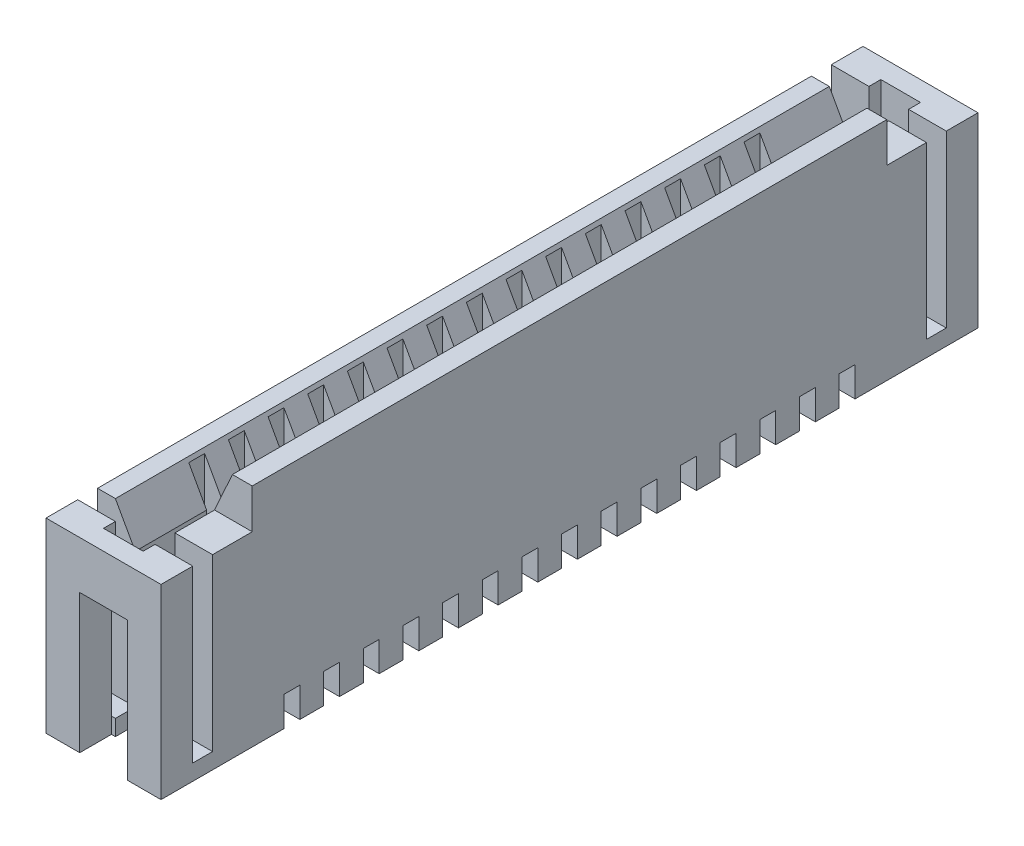
from build123d import *

# Parameters (mm, degrees)
ESBO_O1_W                = 2.9
ESBO_O1_H                = 20.6
RESSALTO_EXTRUS_O1_DEPTH = 4.7
ESBO_O2_W                = 1
ESBO_O2_H                = 19.6
CORTE_EXTRUS_O1_DEPTH    = 4.3
ESBO_O3_W                = 6.892314873
ESBO_O3_H                = 0.5
ESBO_O3_W_2              = 7.332249865
CORTE_EXTRUS_O2_DEPTH    = 4.3
CHANFRO2_SIZE            = 0.5
CHANFRO2_SIZE2           = 0.902023878
RESSALTO_EXTRUS_O2_DEPTH = 8
ESBO_O5_W                = 1
ESBO_O5_H                = 1.1
CORTE_EXTRUS_O3_DEPTH    = 2
ESBO_O6_W                = 1
ESBO_O6_H                = 0.4
RESSALTO_EXTRUS_O3_DEPTH = 2
CORTE_EXTRUS_O4_START    = -4.3
ESBO_O7_W                = 0.7
ESBO_O7_H                = 0.4
CORTE_EXTRUS_O4_DEPTH    = 6.3
ESBO_O8_W                = 0.4
ESBO_O8_H                = 1
CORTE_EXTRUS_O7_DEPTH    = 6.05
PADR_O_LINEAR1_COUNT     = 8
PADR_O_LINEAR1_PITCH     = 1
PADR_O_LINEAR1_COL_COUNT = 8
PADR_O_LINEAR1_COL_PITCH = 1
ESBO_O9_W                = 1.2
ESBO_O9_H                = 4.437339102
CORTE_EXTRUS_O6_DEPTH    = 0.8


with BuildPart() as part:
    # Esboço1 → Ressalto-extrusão1 (new body)
    with BuildSketch(Plane(origin=(0, 0, 0), x_dir=(1, 0, 0), z_dir=(0, 1, 0))):
        Rectangle(ESBO_O1_W, ESBO_O1_H)
    extrude(amount=RESSALTO_EXTRUS_O1_DEPTH)

    # Esboço2 → Corte-extrusão1 (cut)
    with BuildSketch(Plane(origin=(0, 4.7, 0), x_dir=(1, 0, 0), z_dir=(0, 1, 0))):
        Rectangle(ESBO_O2_W, ESBO_O2_H)
    extrude(amount=-CORTE_EXTRUS_O1_DEPTH, mode=Mode.SUBTRACT)

    # Esboço3 → Corte-extrusão2 (cut)
    with BuildSketch(Plane(origin=(0, 4.7, 0), x_dir=(1, 0, 0), z_dir=(0, 1, 0))):
        with Locations((0.16072145, 9.25)):
            Rectangle(ESBO_O3_W, ESBO_O3_H)
        with Locations((0.380688946, -9.25)):
            Rectangle(ESBO_O3_W_2, ESBO_O3_H)
    extrude(amount=-CORTE_EXTRUS_O2_DEPTH, mode=Mode.SUBTRACT)

    # Chanfro2
    chanfro2_edges = [part.edges().sort_by_distance(p)[0] for p in [
        (-0.5, 4.7, 0),
    ]]
    chanfro2_side = [part.faces().sort_by_distance(p)[0] for p in [
        (-0.975, 4.7, 0),
    ]]
    chamfer(chanfro2_edges, length=CHANFRO2_SIZE, length2=CHANFRO2_SIZE2, reference=chanfro2_side[0])

    # Esboço4 → Ressalto-extrusão2 (add, symmetric)
    with BuildSketch(Plane.XY):
        Polygon((1.45, 4.7), (1.45, 5.7), (0.95, 5.7), (0.5, 4.7), align=None)
    extrude(amount=RESSALTO_EXTRUS_O2_DEPTH, both=True)

    # Esboço5 → Corte-extrusão3 (cut)
    with BuildSketch(Plane(origin=(0, 0.4, 0), x_dir=(1, 0, 0), z_dir=(0, 1, 0))):
        with Locations((0, 9.25)):
            Rectangle(ESBO_O5_W, ESBO_O5_H)
        with Locations((0, -9.25)):
            Rectangle(ESBO_O5_W, ESBO_O5_H)
    extrude(amount=-CORTE_EXTRUS_O3_DEPTH, mode=Mode.SUBTRACT)

    # Esboço6 → Ressalto-extrusão3 (add)
    with BuildSketch(Plane(origin=(0, 0.4, 0), x_dir=(1, 0, 0), z_dir=(0, 1, 0))):
        with Locations((0, 8.5)):
            Rectangle(ESBO_O6_W, ESBO_O6_H)
        with Locations((0, -8.5)):
            Rectangle(ESBO_O6_W, ESBO_O6_H)
    extrude(amount=RESSALTO_EXTRUS_O3_DEPTH)

    # Esboço7 → Corte-extrusão4 (cut)
    with BuildSketch(Plane(origin=(0, 4.7, 0), x_dir=(1, 0, 0), z_dir=(0, 1, 0)).offset(CORTE_EXTRUS_O4_START)):
        with Locations((-0.6, 0)):
            Rectangle(ESBO_O7_W, ESBO_O7_H)
        with Locations((0.6, 0)):
            Rectangle(ESBO_O7_W, ESBO_O7_H)
    corte_extrus_o4 = extrude(amount=CORTE_EXTRUS_O4_DEPTH, mode=Mode.SUBTRACT)

    # Esboço8 → Corte-extrusão7 (cut, symmetric)
    with BuildSketch(Plane(origin=(0, 0, 0), x_dir=(0, 0, -1), z_dir=(1, 0, 0))):
        with Locations((0, 0.25)):
            Rectangle(ESBO_O8_W, ESBO_O8_H)
    corte_extrus_o7 = extrude(amount=CORTE_EXTRUS_O7_DEPTH, both=True, mode=Mode.SUBTRACT)

    # Padrão linear1: Corte-extrusão4, Corte-extrusão7 ×8
    with Locations(*[(0, 0, i * PADR_O_LINEAR1_PITCH) for i in range(1, PADR_O_LINEAR1_COUNT)]):
        add(corte_extrus_o4, mode=Mode.SUBTRACT)
        add(corte_extrus_o7, mode=Mode.SUBTRACT)

    # Padrão linear1 col: Corte-extrusão4, Corte-extrusão7 ×8
    with Locations(*[(0, 0, -i * PADR_O_LINEAR1_COL_PITCH) for i in range(1, PADR_O_LINEAR1_COL_COUNT)]):
        add(corte_extrus_o4, mode=Mode.SUBTRACT)
        add(corte_extrus_o7, mode=Mode.SUBTRACT)

    # Esboço9 → Corte-extrusão6 (cut)
    with BuildSketch(Plane.XY.offset(10.3)):
        with Locations((0, 1.281330449)):
            Rectangle(ESBO_O9_W, ESBO_O9_H)
    corte_extrus_o6 = extrude(amount=-CORTE_EXTRUS_O6_DEPTH, mode=Mode.SUBTRACT)

    # Espelhar1: Corte-extrusão6 across plane
    add(corte_extrus_o6.mirror(Plane.XY), mode=Mode.SUBTRACT)


solid = part.part
